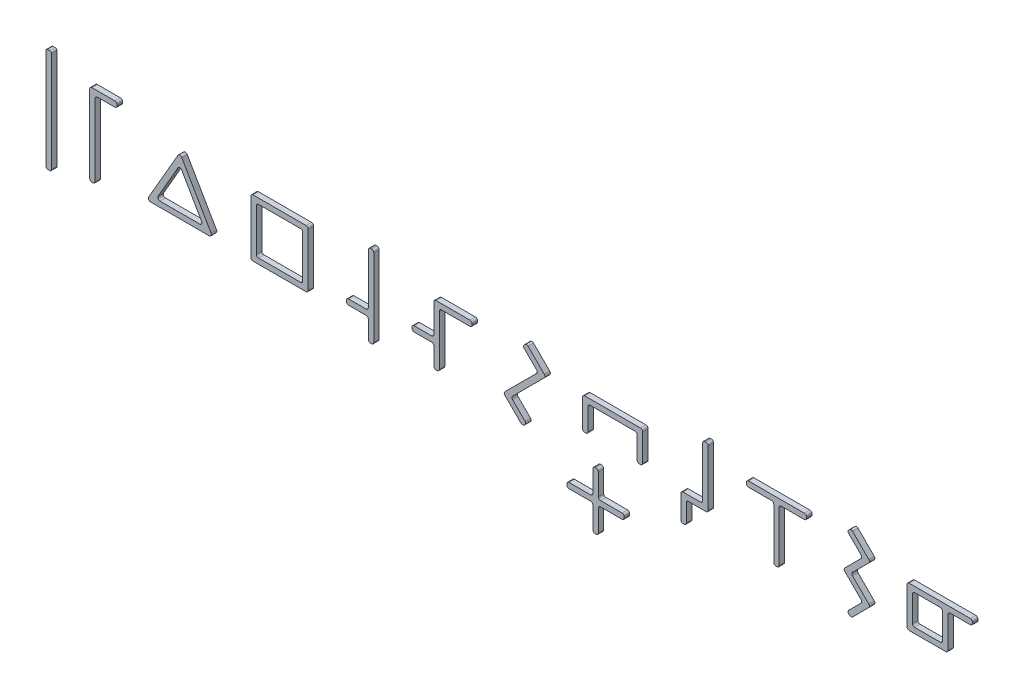
from build123d import *

# Parameters (mm, degrees)
BOSS_EXTRUDE1_DEPTH    = 10
BOSS_EXTRUDE1_2_DEPTH  = 10
BOSS_EXTRUDE1_3_DEPTH  = 10
BOSS_EXTRUDE1_4_DEPTH  = 10
BOSS_EXTRUDE1_5_DEPTH  = 10
BOSS_EXTRUDE1_6_DEPTH  = 10
BOSS_EXTRUDE1_7_DEPTH  = 10
BOSS_EXTRUDE1_8_DEPTH  = 10
BOSS_EXTRUDE1_9_DEPTH  = 10
BOSS_EXTRUDE1_10_DEPTH = 10
BOSS_EXTRUDE1_11_DEPTH = 10
BOSS_EXTRUDE1_12_DEPTH = 10
SKETCH4_W              = 193.679966537
SKETCH4_H              = 295.165410258
CUT_EXTRUDE4_DEPTH     = 11
BOSS_EXTRUDE3_DEPTH    = 10
BOSS_EXTRUDE5_DEPTH    = 10


with BuildPart() as part:
    # Sketch1 → Boss-Extrude1 (new body)
    with BuildSketch(Plane.XY):
        with BuildLine():
            Line((79, 75), (121, 75))
            ThreePointArc((121, 75), (123.828427125, 73.828427125), (125, 71))
            Line((125, 71), (125, 69))
            ThreePointArc((125, 69), (123.828427125, 66.171572875), (121, 65))
            Line((121, 65), (89, 65))
            ThreePointArc((89, 65), (86.171572875, 63.828427125), (85, 61))
            Line((85, 61), (85, -71))
            ThreePointArc((85, -71), (83.828427125, -73.828427125), (81, -75))
            Line((81, -75), (79, -75))
            ThreePointArc((79, -75), (76.171572875, -73.828427125), (75, -71))
            Line((75, -71), (75, 71))
            ThreePointArc((75, 71), (76.171572875, 73.828427125), (79, 75))
        make_face()
    extrude(amount=BOSS_EXTRUDE1_DEPTH)


with BuildPart() as body_2:
    # Sketch1 → Boss-Extrude1 2 (new body)
    with BuildSketch(Plane.XY):
        with BuildLine():
            Line((2, -95), (-2, -95))
            ThreePointArc((-2, -95), (-4.121320344, -94.121320344), (-5, -92))
            Line((-5, -92), (-5, 92))
            ThreePointArc((-5, 92), (-4.121320344, 94.121320344), (-2, 95))
            Line((-2, 95), (2, 95))
            ThreePointArc((2, 95), (4.121320344, 94.121320344), (5, 92))
            Line((5, 92), (5, -92))
            ThreePointArc((5, -92), (4.121320344, -94.121320344), (2, -95))
        make_face()
    extrude(amount=BOSS_EXTRUDE1_2_DEPTH)


with BuildPart() as body_3:
    # Sketch1 → Boss-Extrude1 3 (new body)
    with BuildSketch(Plane.XY):
        with BuildLine():
            Line((237.124891681, 40.328427125), (165, -31.796464556))
            ThreePointArc((165, -31.796464556), (163.828427125, -34.624891681), (165, -37.453318806))
            Line((165, -37.453318806), (166.414213562, -38.867532368))
            ThreePointArc((166.414213562, -38.867532368), (169.242640687, -40.039105243), (172.071067812, -38.867532368))
            Line((172.071067812, -38.867532368), (237.124891681, 26.186291501))
            ThreePointArc((237.124891681, 26.186291501), (239.953318806, 27.357864376), (242.781745931, 26.186291501))
            Line((242.781745931, 26.186291501), (307.8355698, -38.867532368))
            ThreePointArc((307.8355698, -38.867532368), (310.663996924, -40.039105243), (313.492424049, -38.867532368))
            Line((313.492424049, -38.867532368), (314.906637612, -37.453318806))
            ThreePointArc((314.906637612, -37.453318806), (316.078210487, -34.624891681), (314.906637612, -31.796464556))
            Line((314.906637612, -31.796464556), (242.781745931, 40.328427125))
            ThreePointArc((242.781745931, 40.328427125), (239.953318806, 41.5), (237.124891681, 40.328427125))
        make_face()
    extrude(amount=BOSS_EXTRUDE1_3_DEPTH)

    # Sketch4 → Cut-Extrude4 (cut, through all)
    with BuildSketch(Plane.XY):
        with Locations((260.508766095, -43.521766418)):
            Rectangle(SKETCH4_W, SKETCH4_H)
    extrude(amount=CUT_EXTRUDE4_DEPTH, mode=Mode.SUBTRACT)


with BuildPart() as body_4:
    # Sketch1 → Boss-Extrude1 4 (new body)
    with BuildSketch(Plane.XY):
        with BuildLine():
            Line((470.906637612, -52.5), (373.906637612, -52.5))
            ThreePointArc((373.906637612, -52.5), (371.078210487, -51.328427125), (369.906637612, -48.5))
            Line((369.906637612, -48.5), (369.906637612, 48.5))
            ThreePointArc((369.906637612, 48.5), (371.078210487, 51.328427125), (373.906637612, 52.5))
            Line((373.906637612, 52.5), (470.906637612, 52.5))
            ThreePointArc((470.906637612, 52.5), (473.735064736, 51.328427125), (474.906637612, 48.5))
            Line((474.906637612, 48.5), (474.906637612, -48.5))
            ThreePointArc((474.906637612, -48.5), (473.735064736, -51.328427125), (470.906637612, -52.5))
        make_face()
        with BuildLine():
            Line((460.906637612, -42.5), (383.906637612, -42.5))
            ThreePointArc((383.906637612, -42.5), (381.078210487, -41.328427125), (379.906637612, -38.5))
            Line((379.906637612, -38.5), (379.906637612, 38.5))
            ThreePointArc((379.906637612, 38.5), (381.078210487, 41.328427125), (383.906637612, 42.5))
            Line((383.906637612, 42.5), (460.906637612, 42.5))
            ThreePointArc((460.906637612, 42.5), (463.735064736, 41.328427125), (464.906637612, 38.5))
            Line((464.906637612, 38.5), (464.906637612, -38.5))
            ThreePointArc((464.906637612, -38.5), (463.735064736, -41.328427125), (460.906637612, -42.5))
        make_face(mode=Mode.SUBTRACT)
    extrude(amount=BOSS_EXTRUDE1_4_DEPTH)


with BuildPart() as body_5:
    # Sketch1 → Boss-Extrude1 5 (new body)
    with BuildSketch(Plane.XY):
        with BuildLine():
            Line((584.906637612, 71), (584.906637612, -21))
            ThreePointArc((584.906637612, -21), (583.735064736, -23.828427125), (580.906637612, -25))
            Line((580.906637612, -25), (548.906637612, -25))
            ThreePointArc((548.906637612, -25), (546.078210487, -26.171572875), (544.906637612, -29))
            Line((544.906637612, -29), (544.906637612, -31))
            ThreePointArc((544.906637612, -31), (546.078210487, -33.828427125), (548.906637612, -35))
            Line((548.906637612, -35), (580.906637612, -35))
            ThreePointArc((580.906637612, -35), (583.735064736, -36.171572875), (584.906637612, -39))
            Line((584.906637612, -39), (584.906637612, -71))
            ThreePointArc((584.906637612, -71), (586.078210487, -73.828427125), (588.906637612, -75))
            Line((588.906637612, -75), (590.906637612, -75))
            ThreePointArc((590.906637612, -75), (593.735064736, -73.828427125), (594.906637612, -71))
            Line((594.906637612, -71), (594.906637612, 71))
            ThreePointArc((594.906637612, 71), (593.735064736, 73.828427125), (590.906637612, 75))
            Line((590.906637612, 75), (588.906637612, 75))
            ThreePointArc((588.906637612, 75), (586.078210487, 73.828427125), (584.906637612, 71))
        make_face()
    extrude(amount=BOSS_EXTRUDE1_5_DEPTH)


with BuildPart() as body_6:
    # Sketch1 → Boss-Extrude1 6 (new body)
    with BuildSketch(Plane.XY):
        with BuildLine():
            Line((664.906637612, -11.5), (664.906637612, -13.5))
            ThreePointArc((664.906637612, -13.5), (666.078210487, -16.328427125), (668.906637612, -17.5))
            Line((668.906637612, -17.5), (700.906637612, -17.5))
            ThreePointArc((700.906637612, -17.5), (703.735064736, -18.671572875), (704.906637612, -21.5))
            Line((704.906637612, -21.5), (704.906637612, -53.5))
            ThreePointArc((704.906637612, -53.5), (706.078210487, -56.328427125), (708.906637612, -57.5))
            Line((708.906637612, -57.5), (710.906637612, -57.5))
            ThreePointArc((710.906637612, -57.5), (713.735064736, -56.328427125), (714.906637612, -53.5))
            Line((714.906637612, -53.5), (714.906637612, 38.5))
            ThreePointArc((714.906637612, 38.5), (716.078210487, 41.328427125), (718.906637612, 42.5))
            Line((718.906637612, 42.5), (770.906637612, 42.5))
            ThreePointArc((770.906637612, 42.5), (773.735064736, 43.671572875), (774.906637612, 46.5))
            Line((774.906637612, 46.5), (774.906637612, 48.5))
            ThreePointArc((774.906637612, 48.5), (773.735064736, 51.328427125), (770.906637612, 52.5))
            Line((770.906637612, 52.5), (708.906637612, 52.5))
            ThreePointArc((708.906637612, 52.5), (706.078210487, 51.328427125), (704.906637612, 48.5))
            Line((704.906637612, 48.5), (704.906637612, -3.5))
            ThreePointArc((704.906637612, -3.5), (703.735064736, -6.328427125), (700.906637612, -7.5))
            Line((700.906637612, -7.5), (668.906637612, -7.5))
            ThreePointArc((668.906637612, -7.5), (666.078210487, -8.671572875), (664.906637612, -11.5))
        make_face()
    extrude(amount=BOSS_EXTRUDE1_6_DEPTH)


with BuildPart() as body_7:
    # Sketch1 → Boss-Extrude1 7 (new body)
    with BuildSketch(Plane.XY):
        with BuildLine():
            Line((870.261976671, 62.932503526), (871.676190233, 64.346717088))
            ThreePointArc((871.676190233, 64.346717088), (874.504617358, 65.518289963), (877.333044483, 64.346717088))
            Line((877.333044483, 64.346717088), (907.031529293, 34.648232278))
            ThreePointArc((907.031529293, 34.648232278), (908.203102168, 31.819805153), (907.031529293, 28.991378029))
            Line((907.031529293, 28.991378029), (849.048773235, -28.991378029))
            ThreePointArc((849.048773235, -28.991378029), (847.87720036, -31.819805153), (849.048773235, -34.648232278))
            Line((849.048773235, -34.648232278), (871.676190233, -57.275649276))
            ThreePointArc((871.676190233, -57.275649276), (872.847763109, -60.104076401), (871.676190233, -62.932503526))
            Line((871.676190233, -62.932503526), (870.261976671, -64.346717088))
            ThreePointArc((870.261976671, -64.346717088), (867.433549546, -65.518289963), (864.605122421, -64.346717088))
            Line((864.605122421, -64.346717088), (834.906637612, -34.648232278))
            ThreePointArc((834.906637612, -34.648232278), (833.735064736, -31.819805153), (834.906637612, -28.991378029))
            Line((834.906637612, -28.991378029), (892.889393669, 28.991378029))
            ThreePointArc((892.889393669, 28.991378029), (894.060966544, 31.819805153), (892.889393669, 34.648232278))
            Line((892.889393669, 34.648232278), (870.261976671, 57.275649276))
            ThreePointArc((870.261976671, 57.275649276), (869.090403796, 60.104076401), (870.261976671, 62.932503526))
        make_face()
    extrude(amount=BOSS_EXTRUDE1_7_DEPTH)


with BuildPart() as body_8:
    # Sketch1 → Boss-Extrude1 8 (new body)
    with BuildSketch(Plane.XY):
        with BuildLine():
            Line((977.031529293, 33.5), (977.031529293, -16.5))
            ThreePointArc((977.031529293, -16.5), (978.203102168, -19.328427125), (981.031529293, -20.5))
            Line((981.031529293, -20.5), (983.031529293, -20.5))
            ThreePointArc((983.031529293, -20.5), (985.859956417, -19.328427125), (987.031529293, -16.5))
            Line((987.031529293, -16.5), (987.031529293, 23.5))
            ThreePointArc((987.031529293, 23.5), (988.203102168, 26.328427125), (991.031529293, 27.5))
            Line((991.031529293, 27.5), (1073.031529293, 27.5))
            ThreePointArc((1073.031529293, 27.5), (1075.859956417, 26.328427125), (1077.031529293, 23.5))
            Line((1077.031529293, 23.5), (1077.031529293, -16.5))
            ThreePointArc((1077.031529293, -16.5), (1078.203102168, -19.328427125), (1081.031529293, -20.5))
            Line((1081.031529293, -20.5), (1083.031529293, -20.5))
            ThreePointArc((1083.031529293, -20.5), (1085.859956417, -19.328427125), (1087.031529293, -16.5))
            Line((1087.031529293, -16.5), (1087.031529293, 33.5))
            ThreePointArc((1087.031529293, 33.5), (1085.859956417, 36.328427125), (1083.031529293, 37.5))
            Line((1083.031529293, 37.5), (981.031529293, 37.5))
            ThreePointArc((981.031529293, 37.5), (978.203102168, 36.328427125), (977.031529293, 33.5))
        make_face()
    extrude(amount=BOSS_EXTRUDE1_8_DEPTH)


with BuildPart() as body_9:
    # Sketch1 → Boss-Extrude1 9 (new body)
    with BuildSketch(Plane.XY):
        with BuildLine():
            Line((1157.031529293, -29), (1157.031529293, -71))
            ThreePointArc((1157.031529293, -71), (1158.203102168, -73.828427125), (1161.031529293, -75))
            Line((1161.031529293, -75), (1163.031529293, -75))
            ThreePointArc((1163.031529293, -75), (1165.859956417, -73.828427125), (1167.031529293, -71))
            Line((1167.031529293, -71), (1167.031529293, -39))
            ThreePointArc((1167.031529293, -39), (1168.203102168, -36.171572875), (1171.031529293, -35))
            Line((1171.031529293, -35), (1203.031529293, -35))
            ThreePointArc((1203.031529293, -35), (1205.859956417, -33.828427125), (1207.031529293, -31))
            Line((1207.031529293, -31), (1207.031529293, 71))
            ThreePointArc((1207.031529293, 71), (1205.859956417, 73.828427125), (1203.031529293, 75))
            Line((1203.031529293, 75), (1201.031529293, 75))
            ThreePointArc((1201.031529293, 75), (1198.203102168, 73.828427125), (1197.031529293, 71))
            Line((1197.031529293, 71), (1197.031529293, -21))
            ThreePointArc((1197.031529293, -21), (1195.859956417, -23.828427125), (1193.031529293, -25))
            Line((1193.031529293, -25), (1161.031529293, -25))
            ThreePointArc((1161.031529293, -25), (1158.203102168, -26.171572875), (1157.031529293, -29))
        make_face()
    extrude(amount=BOSS_EXTRUDE1_9_DEPTH)


with BuildPart() as body_10:
    # Sketch1 → Boss-Extrude1 10 (new body)
    with BuildSketch(Plane.XY):
        with BuildLine():
            Line((1277.031529293, 48.5), (1277.031529293, 46.5))
            ThreePointArc((1277.031529293, 46.5), (1278.203102168, 43.671572875), (1281.031529293, 42.5))
            Line((1281.031529293, 42.5), (1323.031529293, 42.5))
            ThreePointArc((1323.031529293, 42.5), (1325.859956417, 41.328427125), (1327.031529293, 38.5))
            Line((1327.031529293, 38.5), (1327.031529293, -53.5))
            ThreePointArc((1327.031529293, -53.5), (1328.203102168, -56.328427125), (1331.031529293, -57.5))
            Line((1331.031529293, -57.5), (1333.031529293, -57.5))
            ThreePointArc((1333.031529293, -57.5), (1335.859956417, -56.328427125), (1337.031529293, -53.5))
            Line((1337.031529293, -53.5), (1337.031529293, 38.5))
            ThreePointArc((1337.031529293, 38.5), (1338.203102168, 41.328427125), (1341.031529293, 42.5))
            Line((1341.031529293, 42.5), (1383.031529293, 42.5))
            ThreePointArc((1383.031529293, 42.5), (1385.859956417, 43.671572875), (1387.031529293, 46.5))
            Line((1387.031529293, 46.5), (1387.031529293, 48.5))
            ThreePointArc((1387.031529293, 48.5), (1385.859956417, 51.328427125), (1383.031529293, 52.5))
            Line((1383.031529293, 52.5), (1281.031529293, 52.5))
            ThreePointArc((1281.031529293, 52.5), (1278.203102168, 51.328427125), (1277.031529293, 48.5))
        make_face()
    extrude(amount=BOSS_EXTRUDE1_10_DEPTH)


with BuildPart() as body_11:
    # Sketch1 → Boss-Extrude1 11 (new body)
    with BuildSketch(Plane.XY):
        with BuildLine():
            Line((1570.872149726, 33.5), (1570.872149726, -33.5))
            ThreePointArc((1570.872149726, -33.5), (1572.043722601, -36.328427125), (1574.872149726, -37.5))
            Line((1574.872149726, -37.5), (1641.872149726, -37.5))
            ThreePointArc((1641.872149726, -37.5), (1644.700576851, -36.328427125), (1645.872149726, -33.5))
            Line((1645.872149726, -33.5), (1645.872149726, 23.5))
            ThreePointArc((1645.872149726, 23.5), (1647.043722601, 26.328427125), (1649.872149726, 27.5))
            Line((1649.872149726, 27.5), (1686.872149726, 27.5))
            ThreePointArc((1686.872149726, 27.5), (1689.700576851, 28.671572875), (1690.872149726, 31.5))
            Line((1690.872149726, 31.5), (1690.872149726, 33.5))
            ThreePointArc((1690.872149726, 33.5), (1689.700576851, 36.328427125), (1686.872149726, 37.5))
            Line((1686.872149726, 37.5), (1574.872149726, 37.5))
            ThreePointArc((1574.872149726, 37.5), (1572.043722601, 36.328427125), (1570.872149726, 33.5))
        make_face()
        with BuildLine():
            Line((1580.872149726, 23.5), (1580.872149726, -23.5))
            ThreePointArc((1580.872149726, -23.5), (1582.043722601, -26.328427125), (1584.872149726, -27.5))
            Line((1584.872149726, -27.5), (1631.872149726, -27.5))
            ThreePointArc((1631.872149726, -27.5), (1634.700576851, -26.328427125), (1635.872149726, -23.5))
            Line((1635.872149726, -23.5), (1635.872149726, 23.5))
            ThreePointArc((1635.872149726, 23.5), (1634.700576851, 26.328427125), (1631.872149726, 27.5))
            Line((1631.872149726, 27.5), (1584.872149726, 27.5))
            ThreePointArc((1584.872149726, 27.5), (1582.043722601, 26.328427125), (1580.872149726, 23.5))
        make_face(mode=Mode.SUBTRACT)
    extrude(amount=BOSS_EXTRUDE1_11_DEPTH)


with BuildPart() as body_12:
    # Sketch1 → Boss-Extrude1 12 (new body)
    with BuildSketch(Plane.XY):
        with BuildLine():
            Line((1464.213088225, 66.468037432), (1465.627301788, 67.882250994))
            ThreePointArc((1465.627301788, 67.882250994), (1468.455728912, 69.053823869), (1471.284156037, 67.882250994))
            Line((1471.284156037, 67.882250994), (1500.982640847, 38.183766184))
            ThreePointArc((1500.982640847, 38.183766184), (1502.154213722, 35.355339059), (1500.982640847, 32.526911935))
            Line((1500.982640847, 32.526911935), (1471.284156037, 2.828427125))
            ThreePointArc((1471.284156037, 2.828427125), (1470.112583162, 0), (1471.284156037, -2.828427125))
            Line((1471.284156037, -2.828427125), (1500.982640847, -32.526911935))
            ThreePointArc((1500.982640847, -32.526911935), (1502.154213722, -35.355339059), (1500.982640847, -38.183766184))
            Line((1500.982640847, -38.183766184), (1471.284156037, -67.882250994))
            ThreePointArc((1471.284156037, -67.882250994), (1468.455728912, -69.053823869), (1465.627301788, -67.882250994))
            Line((1465.627301788, -67.882250994), (1464.213088225, -66.468037432))
            ThreePointArc((1464.213088225, -66.468037432), (1463.04151535, -63.639610307), (1464.213088225, -60.811183182))
            Line((1464.213088225, -60.811183182), (1486.840505223, -38.183766184))
            ThreePointArc((1486.840505223, -38.183766184), (1488.012078099, -35.355339059), (1486.840505223, -32.526911935))
            Line((1486.840505223, -32.526911935), (1457.142020413, -2.828427125))
            ThreePointArc((1457.142020413, -2.828427125), (1455.970447538, 0), (1457.142020413, 2.828427125))
            Line((1457.142020413, 2.828427125), (1486.840505223, 32.526911935))
            ThreePointArc((1486.840505223, 32.526911935), (1488.012078099, 35.355339059), (1486.840505223, 38.183766184))
            Line((1486.840505223, 38.183766184), (1464.213088225, 60.811183182))
            ThreePointArc((1464.213088225, 60.811183182), (1463.04151535, 63.639610307), (1464.213088225, 66.468037432))
        make_face()
    extrude(amount=BOSS_EXTRUDE1_12_DEPTH)


with BuildPart() as body_12_2:
    # Sketch5 → Boss-Extrude3 (new body)
    with BuildSketch(Plane.XY):
        with BuildLine():
            Line((236.489217191, 46.5), (182.795642156, -46.5))
            ThreePointArc((182.795642156, -46.5), (182.795642156, -50.5), (186.259743771, -52.5))
            Line((186.259743771, -52.5), (293.64689384, -52.5))
            ThreePointArc((293.64689384, -52.5), (297.110995456, -50.5), (297.110995456, -46.5))
            Line((297.110995456, -46.5), (243.417420421, 46.5))
            ThreePointArc((243.417420421, 46.5), (239.953318806, 48.5), (236.489217191, 46.5))
        make_face()
        with BuildLine():
            Line((203.580251847, -42.5), (276.326385765, -42.5))
            ThreePointArc((276.326385765, -42.5), (279.79048738, -40.5), (279.79048738, -36.5))
            Line((279.79048738, -36.5), (243.417420421, 26.5))
            ThreePointArc((243.417420421, 26.5), (239.953318806, 28.5), (236.489217191, 26.5))
            Line((236.489217191, 26.5), (200.116150232, -36.5))
            ThreePointArc((200.116150232, -36.5), (200.116150232, -40.5), (203.580251847, -42.5))
        make_face(mode=Mode.SUBTRACT)
    extrude(amount=BOSS_EXTRUDE3_DEPTH)


with BuildPart() as body_13:
    # Sketch8 → Boss-Extrude5 (new body)
    with BuildSketch(Plane.XY):
        with BuildLine():
            Line((995.848379219, -70.557395736), (995.848379219, -110.057395736))
            ThreePointArc((995.848379219, -110.057395736), (994.676806343, -112.88582286), (991.848379219, -114.057395736))
            Line((991.848379219, -114.057395736), (952.348379219, -114.057395736))
            ThreePointArc((952.348379219, -114.057395736), (949.519952094, -115.228968611), (948.348379219, -118.057395736))
            Line((948.348379219, -118.057395736), (948.348379219, -120.057395736))
            ThreePointArc((948.348379219, -120.057395736), (949.519952094, -122.88582286), (952.348379219, -124.057395736))
            Line((952.348379219, -124.057395736), (991.848379219, -124.057395736))
            ThreePointArc((991.848379219, -124.057395736), (994.676806343, -125.228968611), (995.848379219, -128.057395736))
            Line((995.848379219, -128.057395736), (995.848379219, -167.557395736))
            ThreePointArc((995.848379219, -167.557395736), (997.019952094, -170.38582286), (999.848379219, -171.557395736))
            Line((999.848379219, -171.557395736), (1001.848379219, -171.557395736))
            ThreePointArc((1001.848379219, -171.557395736), (1004.676806343, -170.38582286), (1005.848379219, -167.557395736))
            Line((1005.848379219, -167.557395736), (1005.848379219, -128.057395736))
            ThreePointArc((1005.848379219, -128.057395736), (1007.019952094, -125.228968611), (1009.848379219, -124.057395736))
            Line((1009.848379219, -124.057395736), (1049.348379219, -124.057395736))
            ThreePointArc((1049.348379219, -124.057395736), (1052.176806343, -122.88582286), (1053.348379219, -120.057395736))
            Line((1053.348379219, -120.057395736), (1053.348379219, -118.057395736))
            ThreePointArc((1053.348379219, -118.057395736), (1052.176806343, -115.228968611), (1049.348379219, -114.057395736))
            Line((1049.348379219, -114.057395736), (1009.848379219, -114.057395736))
            ThreePointArc((1009.848379219, -114.057395736), (1007.019952094, -112.88582286), (1005.848379219, -110.057395736))
            Line((1005.848379219, -110.057395736), (1005.848379219, -70.557395736))
            ThreePointArc((1005.848379219, -70.557395736), (1004.676806343, -67.728968611), (1001.848379219, -66.557395736))
            Line((1001.848379219, -66.557395736), (999.848379219, -66.557395736))
            ThreePointArc((999.848379219, -66.557395736), (997.019952094, -67.728968611), (995.848379219, -70.557395736))
        make_face()
    extrude(amount=BOSS_EXTRUDE5_DEPTH)


solid = Compound([part.part, body_2.part, body_4.part, body_5.part, body_6.part, body_7.part, body_8.part, body_9.part, body_10.part, body_11.part, body_12.part, body_12_2.part, body_13.part])
